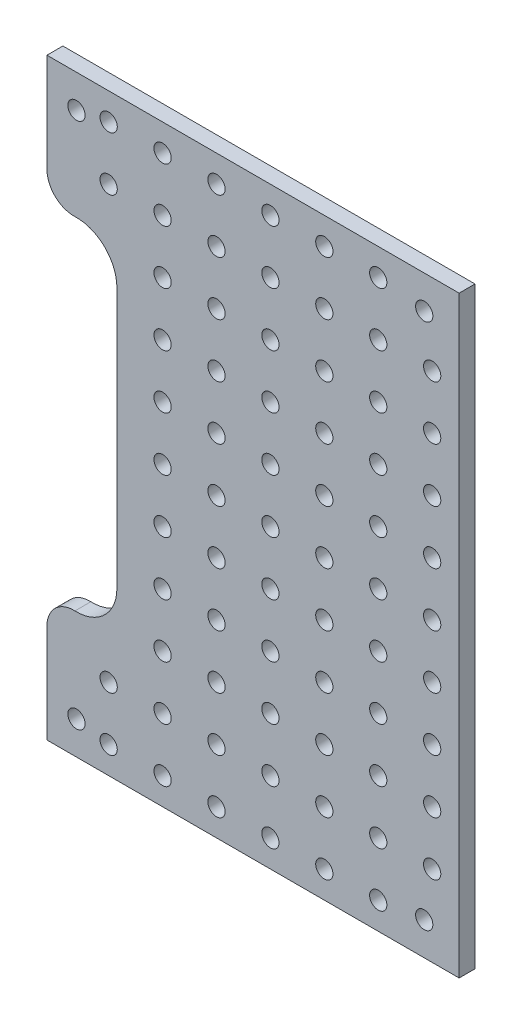
from build123d import *

# Parameters (mm, degrees)
SKETCH1_R            = 1.6
BOSS_EXTRUDE1_DEPTH  = 2.95
FILLET1_R            = 5
M3_CLEARANCE_HOLE3_D = 3.2
LPATTERN3_COUNT      = 7
LPATTERN3_PITCH      = 10
LPATTERN3_COUNT_DIR2 = 11
LPATTERN3_PITCH_DIR2 = 10


with BuildPart() as part:
    # Sketch1 → Boss-Extrude1 (new body)
    with BuildSketch(Plane.XY):
        with BuildLine():
            Line((3.56, -29.301188946), (3.56, -55))
            Line((3.56, -55), (80, -55))
            Line((80, -55), (80, 55))
            Line((80, 55), (3.56, 55))
            Line((3.56, 55), (3.56, 29.301188946))
            ThreePointArc((3.56, 29.301188946), (11.789075932, 31.144059076), (16.53, 24.17))
            Line((16.53, 24.17), (16.53, -24.17))
            ThreePointArc((16.53, -24.17), (11.789075932, -31.144059076), (3.56, -29.301188946))
        make_face()
        with Locations((9.03, -48.875)):
            Circle(SKETCH1_R, mode=Mode.SUBTRACT)
        with Locations((73.525, -48.875)):
            Circle(SKETCH1_R, mode=Mode.SUBTRACT)
        with Locations((9.03, 48.875)):
            Circle(SKETCH1_R, mode=Mode.SUBTRACT)
        with Locations((73.525, 48.875)):
            Circle(SKETCH1_R, mode=Mode.SUBTRACT)
    extrude(amount=BOSS_EXTRUDE1_DEPTH)

    # Fillet1
    fillet1_edges = [part.edges().sort_by_distance(p)[0] for p in [
        (3.56, 29.301188946, 1.475),
        (3.56, -29.301188946, 1.475),
    ]]
    fillet(fillet1_edges, radius=FILLET1_R)

    # M3 Clearance Hole3 (through all)
    with Locations(Plane(origin=(0, 0, 0), x_dir=(-1, 0, 0), z_dir=(0, 0, -1))):
        with Locations((-15, -50)):
            m3_clearance_hole3 = Hole(M3_CLEARANCE_HOLE3_D / 2)

    # LPattern3: M3 Clearance Hole3 7 × 11, 9 skipped
    with Locations(*[(i * LPATTERN3_PITCH, j * LPATTERN3_PITCH_DIR2, 0) for i in range(LPATTERN3_COUNT) for j in range(LPATTERN3_COUNT_DIR2) if (i, j) not in ((0, 0), (0, 2), (0, 3), (0, 4), (0, 5), (0, 6), (0, 7), (0, 8), (6, 0), (6, 10))]):
        add(m3_clearance_hole3, mode=Mode.SUBTRACT)


solid = part.part
